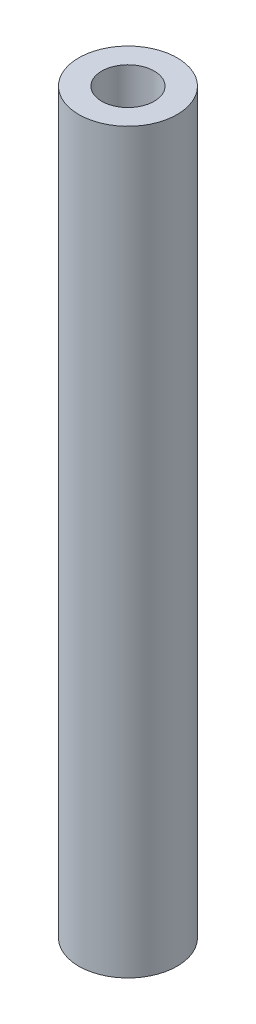
from build123d import *

# Parameters (mm, degrees)
SKETCH_1_R      = 3
SKETCH_1_R_2    = 1.6
EXTRUDE_1_DEPTH = 45


with BuildPart() as part:
    # 草图1 → 凸台-拉伸1 (new body)
    with BuildSketch(Plane(origin=(0, 0, 0), x_dir=(1, 0, 0), z_dir=(0, 1, 0))):
        Circle(SKETCH_1_R)
        Circle(SKETCH_1_R_2, mode=Mode.SUBTRACT)
    extrude(amount=EXTRUDE_1_DEPTH)


solid = part.part
